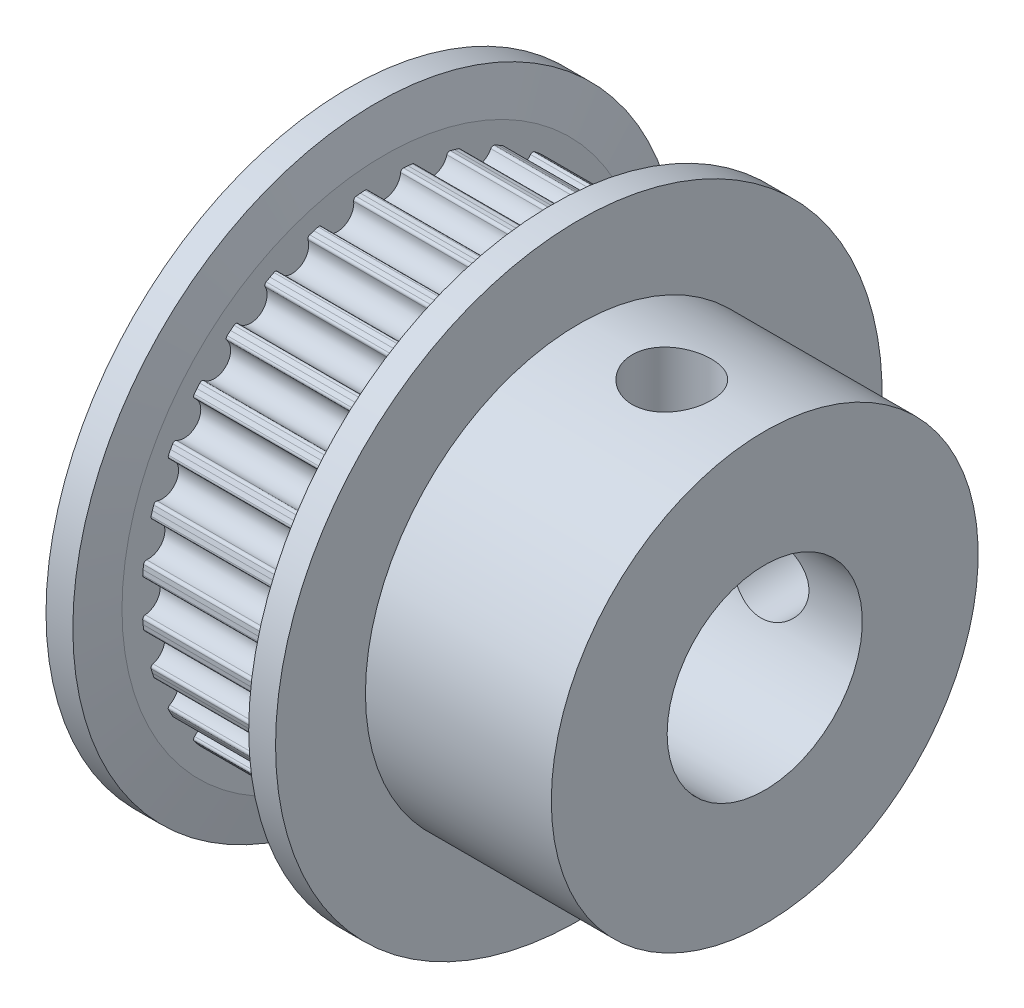
from build123d import *

# Parameters (mm, degrees)
CUT_EXTRUDE1_DEPTH = 6.55
CIRPATTERN1_COUNT  = 32
SKETCH39_R         = 4.001
CUT_EXTRUDE2_DEPTH = 17.03
SKETCH37_W         = 1.621
SKETCH37_H         = 9.93
CIRPATTERN2_COUNT  = 2
CIRPATTERN2_ANGLE  = 90


with BuildPart() as part:
    # Sketch1 → Revolve1 (revolve)
    with BuildSketch(Plane.XY):
        Polygon((0, 0), (0, 8.75), (1.43, 8.75), (1.43, 10.088071429), (7.98, 10.088071429), (7.98, 8.75), (17.03, 8.75), (17.03, 0), align=None)
    revolve(axis=Axis((17.03, 0, 0), (-1, 0, 0)))

    # Sketch2 → Cut-Extrude1 (cut)
    with BuildSketch(Plane(origin=(1.43, 0, 0), x_dir=(0, 0, -1), z_dir=(1, 0, 0))):
        with BuildLine():
            Line((-1.03437385, 9.879953537), (-1.057813893, 10.129918794))
            ThreePointArc((-1.057813893, 10.129918794), (0, 10.185), (1.057813893, 10.129918794))
            Line((1.057813893, 10.129918794), (1.03437385, 9.879953537))
            Line((1.03437385, 9.879953537), (0.792969158, 9.89929093))
            ThreePointArc((0.792969158, 9.89929093), (0.711706777, 9.87316989), (0.672449407, 9.797375812))
            ThreePointArc((0.672449407, 9.797375812), (0, 9.181), (-0.672449407, 9.797375812))
            ThreePointArc((-0.672449407, 9.797375812), (-0.711706777, 9.87316989), (-0.792969158, 9.89929093))
            Line((-0.792969158, 9.89929093), (-1.03437385, 9.879953537))
        make_face()
    cut_extrude1 = extrude(amount=CUT_EXTRUDE1_DEPTH, mode=Mode.SUBTRACT)

    # CirPattern1: Cut-Extrude1 ×32 about axis
    cirpattern1_axis = Axis((0, 0, 0), (1, 0, 0))
    for i in range(1, CIRPATTERN1_COUNT):
        add(cut_extrude1.rotate(cirpattern1_axis, i * 360 / CIRPATTERN1_COUNT), mode=Mode.SUBTRACT)

    # Sketch34 → Revolve2 (revolve)
    with BuildSketch(Plane.XY):
        Polygon((7.98, 8.75), (7.98, 10.75), (8.31, 12.435), (9.41, 12.435), (9.41, 8.75), align=None)
        Polygon((1.43, 8.75), (1.43, 10.75), (1.1, 12.435), (0, 12.435), (0, 8.76), (0.01, 8.75), align=None)
    revolve(axis=Axis((17.03, 0, 0), (-1, 0, 0)))

    # Sketch39 → Cut-Extrude2 (cut)
    with BuildSketch(Plane.ZY):
        Circle(SKETCH39_R)
    extrude(amount=-CUT_EXTRUDE2_DEPTH, mode=Mode.SUBTRACT)

    # Sketch37 → Cut-Revolve2 (revolve, cut)
    with BuildSketch(Plane(origin=(13.22, 0, 0), x_dir=(0, 0, -1), z_dir=(1, 0, 0))):
        with Locations((0.8105, 4.965)):
            Rectangle(SKETCH37_W, SKETCH37_H)
    cut_revolve2 = revolve(axis=Axis((13.22, 0, 0), (0, 1, 0)), mode=Mode.SUBTRACT)

    # CirPattern2: Cut-Revolve2 ×2 about axis
    cirpattern2_axis = Axis((17.03, 0, 0), (-1, 0, 0))
    for i in range(1, CIRPATTERN2_COUNT):
        add(cut_revolve2.rotate(cirpattern2_axis, i * CIRPATTERN2_ANGLE / (CIRPATTERN2_COUNT - 1)), mode=Mode.SUBTRACT)


solid = part.part
